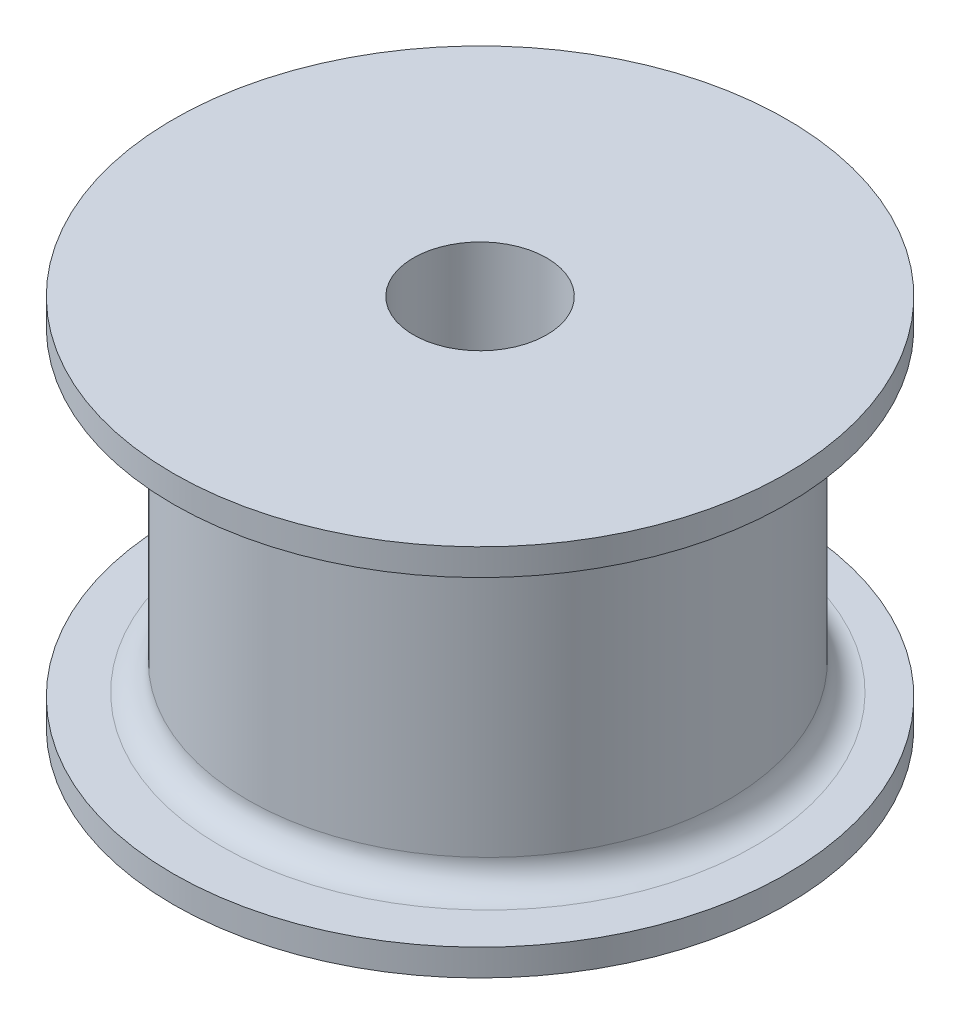
from build123d import *

# Parameters (mm, degrees)
SKETCH1_R           = 4.95
BOSS_EXTRUDE2_DEPTH = 0.001
SKETCH4_R           = 11.5
BOSS_EXTRUDE3_DEPTH = 1
SKETCH5_R           = 9
BOSS_EXTRUDE4_DEPTH = 12
SKETCH6_R           = 11.5
BOSS_EXTRUDE5_DEPTH = 1
FILLET1_R           = 1
FILLET2_R           = 1
SKETCH7_R           = 2.5
CUT_EXTRUDE1_DEPTH  = 15.001


with BuildPart() as part:
    # Sketch1 → Boss-Extrude2 (new body)
    with BuildSketch(Plane(origin=(0, 0, 0), x_dir=(1, 0, 0), z_dir=(0, 1, 0))):
        Circle(SKETCH1_R)
    extrude(amount=BOSS_EXTRUDE2_DEPTH)

    # Sketch4 → Boss-Extrude3 (add)
    with BuildSketch(Plane(origin=(0, 0.001, 0), x_dir=(1, 0, 0), z_dir=(0, 1, 0))):
        Circle(SKETCH4_R)
    extrude(amount=BOSS_EXTRUDE3_DEPTH)

    # Sketch5 → Boss-Extrude4 (add)
    with BuildSketch(Plane(origin=(0, 1.001, 0), x_dir=(1, 0, 0), z_dir=(0, 1, 0))):
        with Locations((0, 0.291114712)):
            Circle(SKETCH5_R)
    extrude(amount=BOSS_EXTRUDE4_DEPTH)

    # Sketch6 → Boss-Extrude5 (add)
    with BuildSketch(Plane(origin=(0, 13.001, 0), x_dir=(1, 0, 0), z_dir=(0, 1, 0))):
        Circle(SKETCH6_R)
    extrude(amount=BOSS_EXTRUDE5_DEPTH)

    # Fillet1
    fillet1_edges = [part.edges().sort_by_distance(p)[0] for p in [
        (-9, 1.001, -0.291114712),
    ]]
    fillet(fillet1_edges, radius=FILLET1_R)

    # Fillet2
    fillet2_edges = [part.edges().sort_by_distance(p)[0] for p in [
        (-9, 13.001, -0.291114712),
    ]]
    fillet(fillet2_edges, radius=FILLET2_R)

    # Sketch7 → Cut-Extrude1 (cut, through all)
    with BuildSketch(Plane.XZ):
        Circle(SKETCH7_R)
    extrude(amount=-CUT_EXTRUDE1_DEPTH, mode=Mode.SUBTRACT)


solid = part.part
